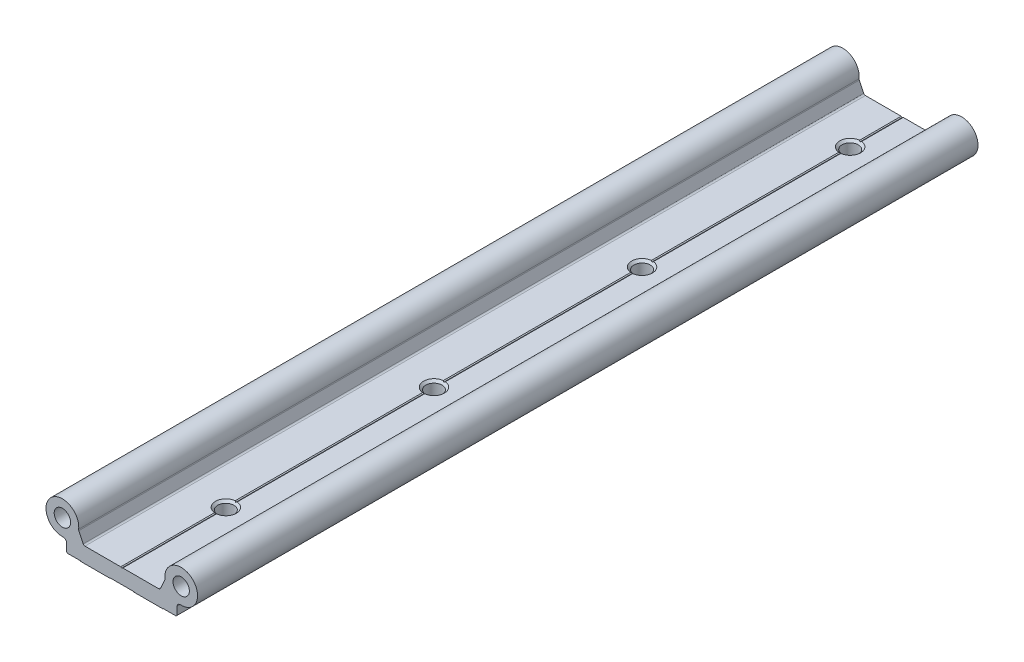
from build123d import *

# Parameters (mm, degrees)
MODEL_R                           = 3.999999997
BOSS_EXTRUDE1_DEPTH               = 381
F_3_8_16_TAPPED_HOLE1_D           = 7.9375
F_3_8_16_TAPPED_HOLE1_CSINK_D     = 10.16
F_3_8_16_TAPPED_HOLE1_CSINK_ANGLE = 90


with BuildPart() as part:
    # Model → Boss-Extrude1 (new body)
    with BuildSketch(Plane.XY):
        with BuildLine():
            Line((-18.843780991, 7.981867858), (-20.966888929, 12.534890876))
            ThreePointArc((-20.966888929, 12.534890876), (-21.047789267, 12.798072701), (-21.053849819, 13.07334131))
            ThreePointArc((-21.053849819, 13.07334131), (-34.474612004, 19.833405747), (-28.578947374, 6.011088019))
            ThreePointArc((-28.578947374, 6.011088019), (-27.4676292, 5.601381399), (-27.000000001, 4.513167022))
            Line((-27.000000001, 4.513167022), (-27.000000001, 0.700000022))
            Line((-27.000000001, 0.700000022), (-26.500000001, 0.200000022))
            Line((-26.500000001, 0.200000022), (-20.200001001, 0.200000022))
            Line((-20.200001001, 0.200000022), (-20.000000979, 0))
            Line((-20.000000979, 0), (-6.000000502, 0))
            Line((-6.000000502, 0), (-5.80000048, 0.200000022))
            Line((-5.80000048, 0.200000022), (5.80000048, 0.200000022))
            Line((5.80000048, 0.200000022), (6.000000502, 0))
            Line((6.000000502, 0), (20.000000979, 0))
            Line((20.000000979, 0), (20.200001001, 0.200000022))
            Line((20.200001001, 0.200000022), (26.500000001, 0.200000022))
            Line((26.500000001, 0.200000022), (27.000000001, 0.700000022))
            Line((27.000000001, 0.700000022), (27.000000001, 4.513167022))
            ThreePointArc((27.000000001, 4.513167022), (27.4676292, 5.601381399), (28.578947374, 6.011088019))
            ThreePointArc((28.578947374, 6.011088019), (34.474612004, 19.833405747), (21.053849819, 13.07334131))
            ThreePointArc((21.053849819, 13.07334131), (21.047789267, 12.798072701), (20.966888929, 12.534890876))
            Line((20.966888929, 12.534890876), (18.843780991, 7.981867858))
            ThreePointArc((18.843780991, 7.981867858), (18.479330527, 7.628755749), (17.98848008, 7.499999621))
            Line((17.98848008, 7.499999621), (0.500000254, 7.499999621))
            Line((0.500000254, 7.499999621), (0, 7.211324621))
            Line((0, 7.211324621), (-0.500000254, 7.499999621))
            Line((-0.500000254, 7.499999621), (-17.98848008, 7.499999621))
            ThreePointArc((-17.98848008, 7.499999621), (-18.479330527, 7.628755749), (-18.843780991, 7.981867858))
        make_face()
        with Locations((-29.000000026, 13.999999962)):
            Circle(MODEL_R, mode=Mode.SUBTRACT)
        with Locations((29.000000026, 13.999999962)):
            Circle(MODEL_R, mode=Mode.SUBTRACT)
    extrude(amount=BOSS_EXTRUDE1_DEPTH)

    # 3/8-16 Tapped Hole1 (through all)
    with Locations(Plane(origin=(0, 7.499999621, 0), x_dir=(1, 0, 0), z_dir=(0, 1, 0))):
        with Locations((0, -25.4), (0, -127), (0, -228.6), (0, -330.2), (0, -431.8), (0, -533.4), (0, -635), (0, -736.6), (0, -838.2), (0, -939.8), (0, -1041.4), (0, -1143), (0, -1244.6), (0, -1346.2), (0, -1447.8), (0, -1549.4), (0, -1651), (0, -1752.6), (0, -1854.2), (0, -1955.8)):
            CounterSinkHole(F_3_8_16_TAPPED_HOLE1_D / 2, F_3_8_16_TAPPED_HOLE1_CSINK_D / 2, counter_sink_angle=F_3_8_16_TAPPED_HOLE1_CSINK_ANGLE)


solid = part.part
